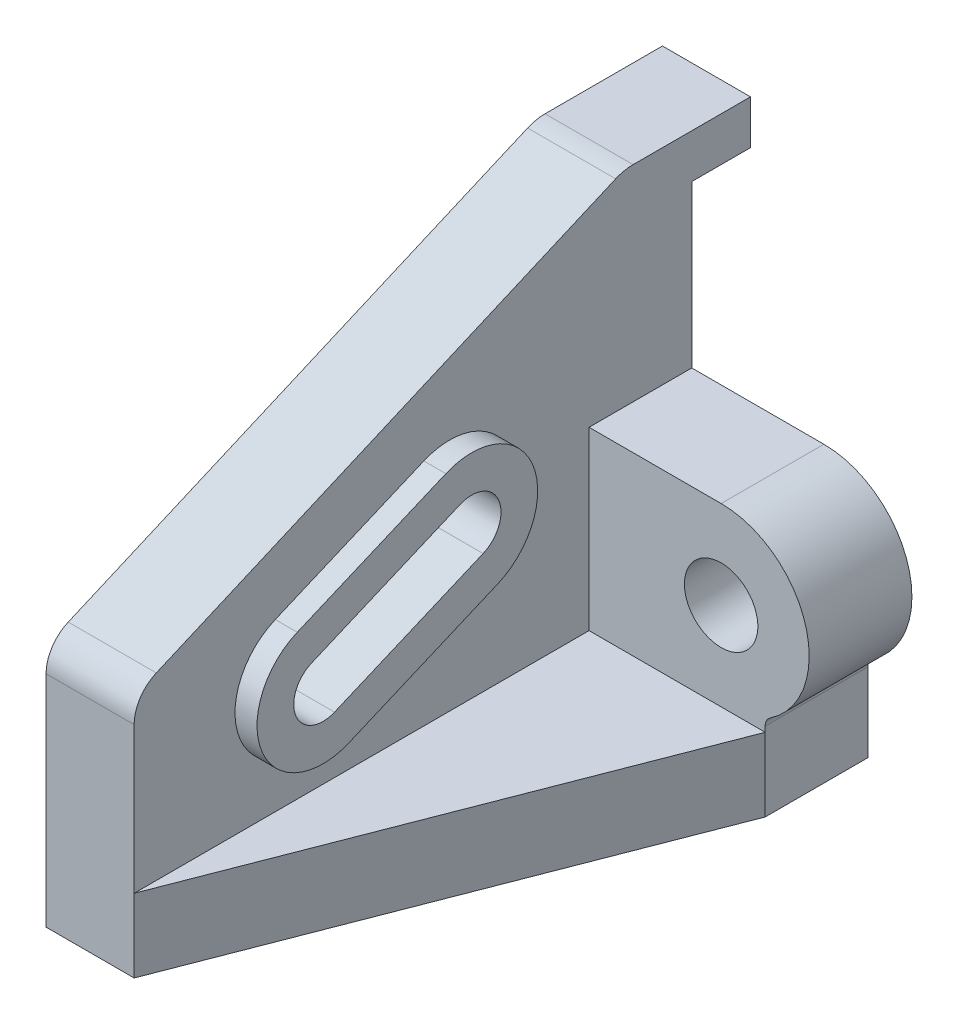
from build123d import *

# Parameters (mm, degrees)
BOSS_EXTRUDE1_DEPTH = 19.05
BOSS_EXTRUDE2_START = 19.05
BOSS_EXTRUDE2_DEPTH = 4.7625
BOSS_EXTRUDE3_START = 19.05
BOSS_EXTRUDE3_DEPTH = 38.1
CUT_EXTRUDE1_DEPTH  = 16.875
SKETCH3_R           = 7.9375
BOSS_EXTRUDE5_DEPTH = 22.225
FILLET1_R           = 2.54


with BuildPart() as part:
    # Sketch1 → Boss-Extrude1 (new body)
    with BuildSketch(Plane(origin=(0, 0, 0), x_dir=(0, 0, -1), z_dir=(1, 0, 0))):
        with BuildLine():
            Line((0, 31.600913244), (0, 0))
            Line((0, 0), (98.425, 0))
            Line((98.425, 0), (98.425, 6.35))
            Line((98.425, 6.35), (120.65, 6.35))
            Line((120.65, 6.35), (120.65, 73.025))
            Line((120.65, 73.025), (133.35, 73.025))
            Line((133.35, 73.025), (133.35, 82.55))
            Line((133.35, 82.55), (107.95, 82.55))
            ThreePointArc((107.95, 82.55), (106.023410696, 82.353122997), (104.176464673, 81.770630688))
            Line((104.176464673, 81.770630688), (4.792887228, 38.888938818))
            ThreePointArc((4.792887228, 38.888938818), (1.305597176, 35.962308799), (0, 31.600913244))
        make_face()
        with BuildLine():
            ThreePointArc((41.696438991, 9.714502244), (22.962154899, 17.283644339), (30.531296995, 36.017928431))
            Line((30.531296995, 36.017928431), (62.679929002, 49.664213094))
            ThreePointArc((62.679929002, 49.664213094), (81.414213094, 42.095070998), (73.845070998, 23.360786906))
            Line((73.845070998, 23.360786906), (41.696438991, 9.714502244))
        make_face(mode=Mode.SUBTRACT)
        Polygon((98.425, 0), (0, 0), (0, -15.875), (120.65, -15.875), (120.65, 0), (120.65, 6.35), (98.425, 6.35), align=None)
        with BuildLine():
            Line((62.679929002, 49.664213094), (30.531296995, 36.017928431))
            ThreePointArc((30.531296995, 36.017928431), (22.962154899, 17.283644339), (41.696438991, 9.714502244))
            Line((41.696438991, 9.714502244), (73.845070998, 23.360786906))
            ThreePointArc((73.845070998, 23.360786906), (81.414213094, 42.095070998), (62.679929002, 49.664213094))
        make_face()
        with BuildLine():
            ThreePointArc((38.595010659, 17.021009518), (30.268662174, 20.385072672), (33.632725327, 28.711421157))
            Line((33.632725327, 28.711421157), (65.781357334, 42.357705819))
            ThreePointArc((65.781357334, 42.357705819), (74.107705819, 38.993642666), (70.743642666, 30.667294181))
            Line((70.743642666, 30.667294181), (38.595010659, 17.021009518))
        make_face(mode=Mode.SUBTRACT)
    extrude(amount=BOSS_EXTRUDE1_DEPTH)

    # Sketch1_3 → Boss-Extrude2 (add)
    with BuildSketch(Plane(origin=(0, 0, 0), x_dir=(0, 0, -1), z_dir=(1, 0, 0)).offset(BOSS_EXTRUDE2_START)):
        with BuildLine():
            Line((41.696438991, 9.714502244), (73.845070998, 23.360786906))
            ThreePointArc((73.845070998, 23.360786906), (81.414213094, 42.095070998), (62.679929002, 49.664213094))
            Line((62.679929002, 49.664213094), (30.531296995, 36.017928431))
            ThreePointArc((30.531296995, 36.017928431), (22.962154899, 17.283644339), (41.696438991, 9.714502244))
        make_face()
        with BuildLine():
            ThreePointArc((33.632725327, 28.711421157), (30.268662174, 20.385072672), (38.595010659, 17.021009518))
            Line((38.595010659, 17.021009518), (70.743642666, 30.667294181))
            ThreePointArc((70.743642666, 30.667294181), (74.107705819, 38.993642666), (65.781357334, 42.357705819))
            Line((65.781357334, 42.357705819), (33.632725327, 28.711421157))
        make_face(mode=Mode.SUBTRACT)
    extrude(amount=BOSS_EXTRUDE2_DEPTH)

    # Sketch1_4 → Boss-Extrude3 (add)
    with BuildSketch(Plane(origin=(0, 0, 0), x_dir=(0, 0, -1), z_dir=(1, 0, 0)).offset(BOSS_EXTRUDE3_START)):
        Polygon((98.425, 0), (0, 0), (0, -15.875), (120.65, -15.875), (120.65, 0), (120.65, 6.35), (98.425, 6.35), align=None)
    extrude(amount=BOSS_EXTRUDE3_DEPTH)

    # Sketch2 → Cut-Extrude1 (cut, through all)
    with BuildSketch(Plane(origin=(0, 0, 0), x_dir=(1, 0, 0), z_dir=(0, 1, 0))):
        Polygon((19.05, 0), (57.15, 98.425), (57.15, 0), align=None)
    extrude(amount=-CUT_EXTRUDE1_DEPTH, mode=Mode.SUBTRACT)

    # Sketch3 → Boss-Extrude5 (add)
    with BuildSketch(Plane(origin=(0, 0, -120.65), x_dir=(-1, 0, 0), z_dir=(0, 0, -1))):
        with BuildLine():
            Line((-19.05, 0), (-47.625, 0))
            ThreePointArc((-47.625, 0), (-66.675, 19.05), (-47.625, 38.1))
            Line((-47.625, 38.1), (-19.05, 38.1))
            Line((-19.05, 38.1), (-19.05, 0))
        make_face()
        with Locations((-47.625, 19.05)):
            Circle(SKETCH3_R, mode=Mode.SUBTRACT)
    extrude(amount=-BOSS_EXTRUDE5_DEPTH)

    # Fillet1
    fillet1_edges = [part.edges().sort_by_distance(p)[0] for p in [
        (57.15, 2.552216058, -109.5375),
    ]]
    fillet(fillet1_edges, radius=FILLET1_R)


solid = part.part
